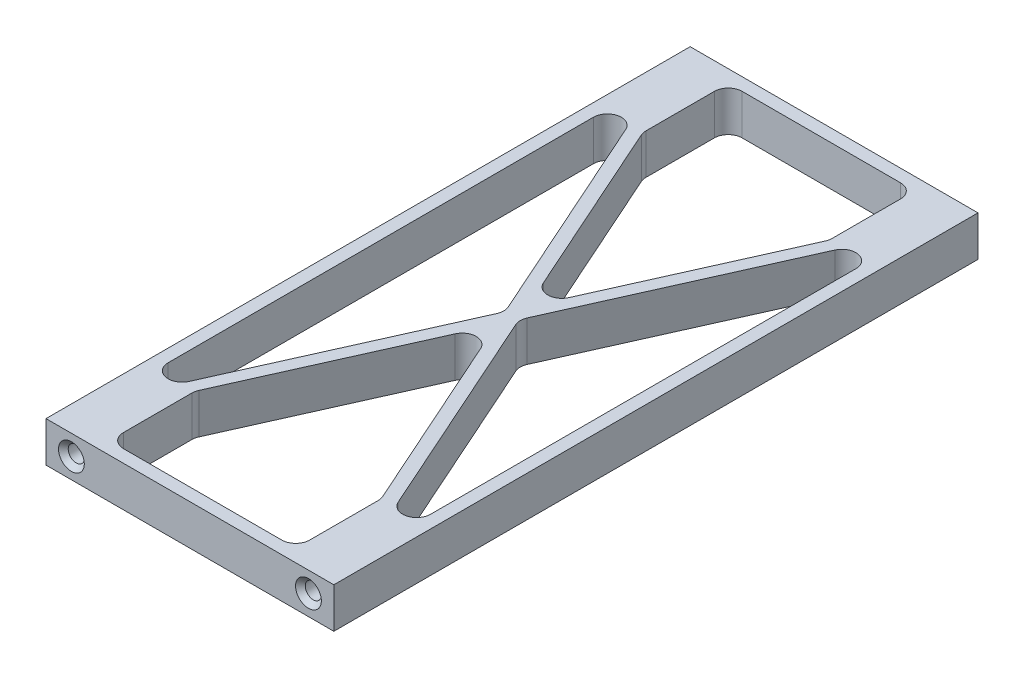
from build123d import *

# Parameters (mm, degrees)
SKETCH1_W                       = 68
SKETCH1_H                       = 152.18109071
BOSS_EXTRUDE1_DEPTH             = 4.7625
CUT_EXTRUDE2_DEPTH              = 10.525
MIRROR3_COPY_1_DEPTH            = 10.525
FILLET1_R                       = 3.3
F_10_24_TAPPED_HOLE1_AT_2_COUNT = 2
F_10_24_TAPPED_HOLE1_AT_2_PITCH = 56


with BuildPart() as part:
    # Sketch1 → Boss-Extrude1 (new body, symmetric)
    with BuildSketch(Plane(origin=(0, 0, 0), x_dir=(1, 0, 0), z_dir=(0, 1, 0))):
        Rectangle(SKETCH1_W, SKETCH1_H)
    extrude(amount=BOSS_EXTRUDE1_DEPTH, both=True)

    # Sketch5 → Cut-Extrude2 (cut, through all)
    with BuildSketch(Plane(origin=(0, 4.7625, 0), x_dir=(1, 0, 0), z_dir=(0, 1, 0))):
        Polygon((-31, -65.699851963), (-31, 0), (-1.642936566, 0), align=None)
        Polygon((-22, -73.090545355), (0, -73.090545355), (0, -3.676821743), (-22, -52.911880502), align=None)
    cut_extrude2 = extrude(amount=-CUT_EXTRUDE2_DEPTH, mode=Mode.SUBTRACT)

    # Mirror2: Cut-Extrude2 across plane
    add(cut_extrude2.mirror(Plane(origin=(0, 0, 0), x_dir=(0, 0, 1), z_dir=(1, 0, 0))), mode=Mode.SUBTRACT)

    # Mirror3: Cut-Extrude2 across plane
    add(cut_extrude2.mirror(Plane.XY), mode=Mode.SUBTRACT)

    # Mirror3 copy 1 sketch → Mirror3 copy 1 (cut, through all)
    with BuildSketch(Plane(origin=(0, 4.7625, 0), x_dir=(-1, 0, 0), z_dir=(0, 1, 0))):
        Polygon((-31, -65.699851963), (-31, 0), (-1.642936566, 0), align=None)
        Polygon((-22, -73.090545355), (0, -73.090545355), (0, -3.676821743), (-22, -52.911880502), align=None)
    extrude(amount=-MIRROR3_COPY_1_DEPTH, mode=Mode.SUBTRACT)

    # Fillet1
    fillet1_edges = [part.edges().sort_by_distance(p)[0] for p in [
        (-1.642936566, 0, 0),
        (-31, 0, 65.699851963),
        (0, 0, 3.676821743),
        (-22, 0, 73.090545355),
        (-22, 0, 52.911880502),
        (31, 0, 65.699851963),
        (1.642936566, 0, 0),
        (22, 0, 52.911880502),
        (22, 0, 73.090545355),
        (31, 0, -65.699851963),
        (0, 0, -3.676821743),
        (22, 0, -73.090545355),
        (22, 0, -52.911880502),
        (-31, 0, -65.699851963),
        (-22, 0, -52.911880502),
        (-22, 0, -73.090545355),
    ]]
    fillet(fillet1_edges, radius=FILLET1_R)

    # Sketch2 → #10-24 Tapped Hole1 (revolve, cut)
    with BuildSketch(Plane(origin=(-28, 0, 76.090545355), x_dir=(0, -1, 0), z_dir=(1, 0, 0))):
        Polygon((0, 0), (0, 16.090824014), (1.89865, 14.95), (1.89865, 1.14935), (3.048, 0), align=None)
    f_10_24_tapped_hole1 = revolve(axis=Axis((-28, 0, 82.440545355), (0, 0, -1)), mode=Mode.SUBTRACT)

    # #10-24 Tapped Hole1 at 2: #10-24 Tapped Hole1 ×2
    with Locations(*[(i * F_10_24_TAPPED_HOLE1_AT_2_PITCH, 0, 0) for i in range(1, F_10_24_TAPPED_HOLE1_AT_2_COUNT)]):
        add(f_10_24_tapped_hole1, mode=Mode.SUBTRACT)

    # Mirror1: #10-24 Tapped Hole1 across plane
    add(f_10_24_tapped_hole1.mirror(Plane.XY), mode=Mode.SUBTRACT)

    # Mirror1 copy 1 sketch → Mirror1 copy 1 (revolve, cut)
    with BuildSketch(Plane(origin=(28, 0, -76.090545355), x_dir=(0, -1, 0), z_dir=(1, 0, 0))):
        Polygon((0, 0), (0, -16.090824014), (1.89865, -14.95), (1.89865, -1.14935), (3.048, 0), align=None)
    revolve(axis=Axis((28, 0, -82.440545355), (0, 0, -1)), mode=Mode.SUBTRACT)


solid = part.part
